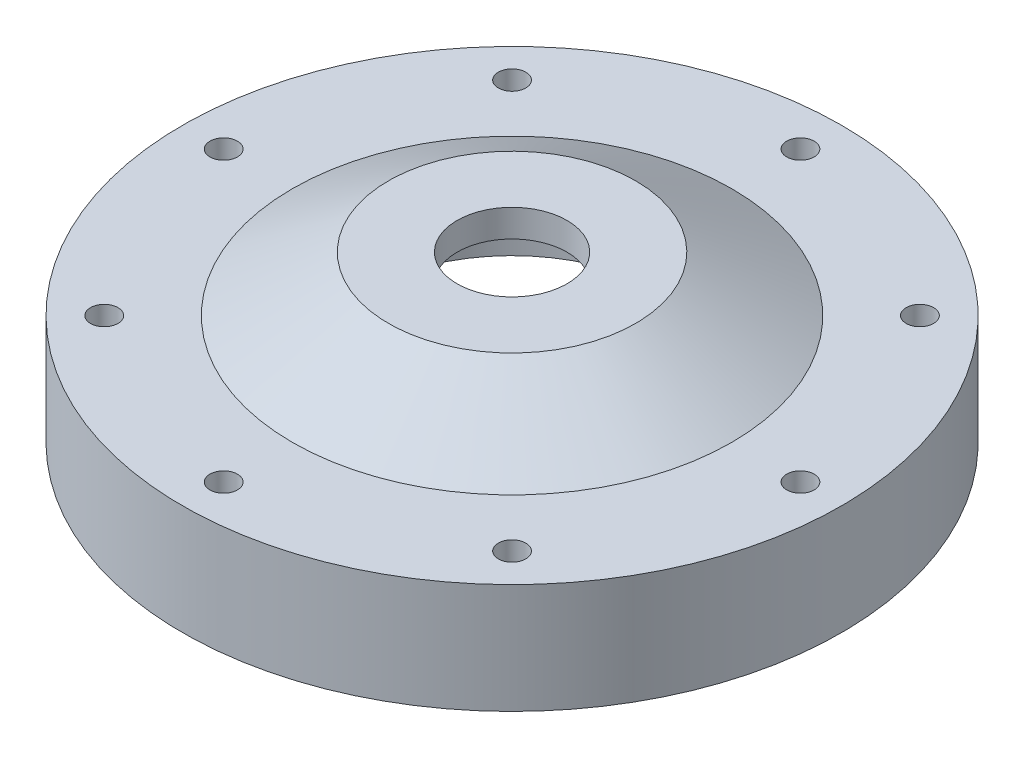
from build123d import *

# Parameters (mm, degrees)
F_1_4_0_25_DIAMETER_HOLE1_D = 6.35
CIRPATTERN1_COUNT           = 8


with BuildPart() as part:
    # Sketch1 → Revolve1 (revolve)
    with BuildSketch(Plane.XY):
        Polygon((-12.7, 0), (-28.575, 0), (-50.8, -12.7), (-76.2, -12.7), (-76.2, -38.1), (-58.3057, -38.1), (-58.3057, -36.068), (-55.5625, -36.068), (-55.5625, -38.1), (-53.975, -38.1), (-53.975, -25.4), (-39.2557, -25.4), (-39.2557, -23.368), (-36.5125, -23.368), (-36.5125, -25.4), (-34.925, -25.4), (-34.925, -19.05), (-12.7, -6.35), align=None)
    revolve(axis=Axis((0, 0, 0), (0, 1, 0)))

    # 1_4 _0.25_ Diameter Hole1 (through all)
    with Locations(Plane(origin=(-66.675, 0, 0), x_dir=(0, 0, 1), z_dir=(0, 1, 0))):
        with Locations((0, 0)):
            f_1_4_0_25_diameter_hole1 = Hole(F_1_4_0_25_DIAMETER_HOLE1_D / 2)

    # CirPattern1: 1_4 _0.25_ Diameter Hole1 ×8 about axis
    cirpattern1_axis = Axis((0, 35.95, 0), (0, -1, 0))
    for i in range(1, CIRPATTERN1_COUNT):
        add(f_1_4_0_25_diameter_hole1.rotate(cirpattern1_axis, i * 360 / CIRPATTERN1_COUNT), mode=Mode.SUBTRACT)


solid = part.part
